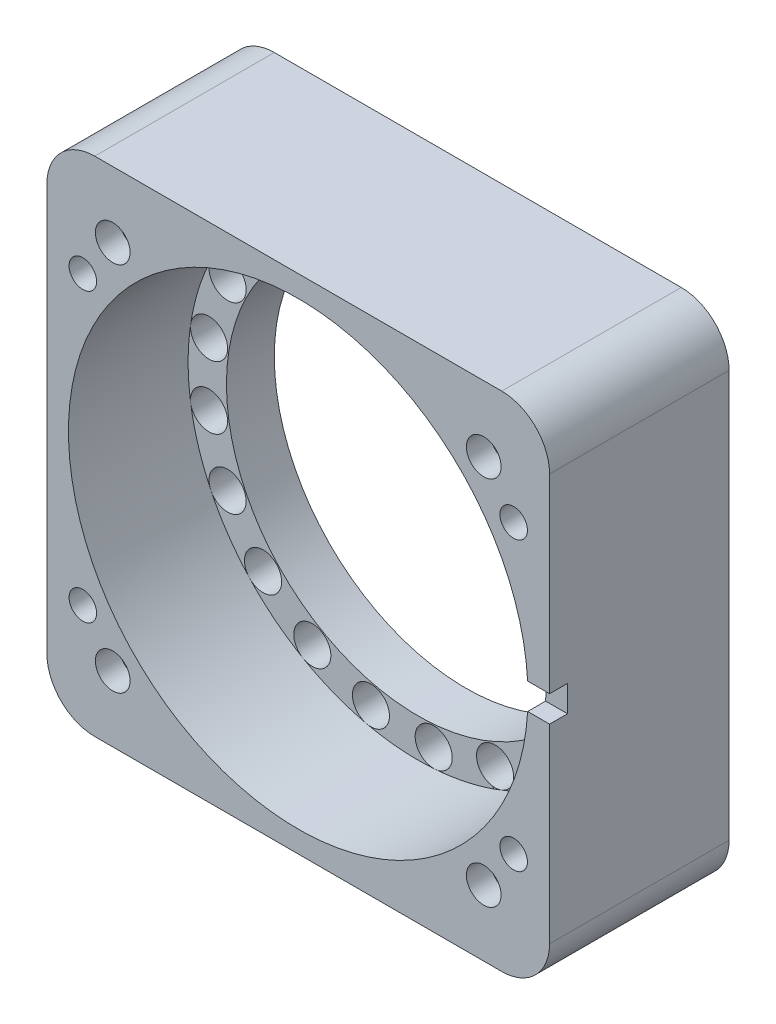
from build123d import *

# Parameters (mm, degrees)
SKETCH_1_W               = 42
SKETCH_1_H               = 42
EXTRUDE_1_DEPTH          = 15
FILLET_2_R               = 4
SKETCH_25_R              = 1.15
CUT_EXTRUDE_16_DEPTH     = 16
SKETCH_28_R              = 1.45
CUT_EXTRUDE_17_DEPTH     = 2
SKETCH_29_R              = 2.15
CUT_EXTRUDE_18_DEPTH     = 6
SKETCH_30_R              = 19.2
CUT_EXTRUDE_19_DEPTH     = 16
SKETCH_31_R              = 19.35
SKETCH_31_R_2            = 16
EXTRUDE_2_DEPTH          = 5
SKETCH_32_R              = 1.55
CUT_EXTRUDE_22_DEPTH     = 3
PATTERN_CIRCULAR_1_COUNT = 21
SKETCH_33_R              = 18.75
CUT_EXTRUDE_23_DEPTH     = 1
SKETCH_34_W              = 5
SKETCH_34_H              = 2.2
CUT_EXTRUDE_24_DEPTH     = 1.5


with BuildPart() as part:
    # 草图1 → 凸台-拉伸1 (new body)
    with BuildSketch(Plane.XY):
        Rectangle(SKETCH_1_W, SKETCH_1_H)
    extrude(amount=EXTRUDE_1_DEPTH)

    # 圆角2
    fillet_2_edges = [part.edges().sort_by_distance(p)[0] for p in [
        (21, 21, 7.5),
        (21, -21, 7.5),
        (-21, -21, 7.5),
        (-21, 21, 7.5),
    ]]
    fillet(fillet_2_edges, radius=FILLET_2_R)

    # 草图25 → 切除-拉伸16 (cut, through all)
    with BuildSketch(Plane.XY.offset(15)):
        with Locations((-18, 12)):
            Circle(SKETCH_25_R)
        with Locations((18, 12)):
            Circle(SKETCH_25_R)
        with Locations((18, -12)):
            Circle(SKETCH_25_R)
        with Locations((-18, -12)):
            Circle(SKETCH_25_R)
    extrude(amount=-CUT_EXTRUDE_16_DEPTH, mode=Mode.SUBTRACT)

    # 草图28 → 切除-拉伸17 (cut)
    with BuildSketch(Plane.XY.offset(15)):
        with Locations((-15.5, 15.5)):
            Circle(SKETCH_28_R)
        with Locations((15.5, 15.5)):
            Circle(SKETCH_28_R)
        with Locations((15.5, -15.5)):
            Circle(SKETCH_28_R)
        with Locations((-15.5, -15.5)):
            Circle(SKETCH_28_R)
    extrude(amount=-CUT_EXTRUDE_17_DEPTH, mode=Mode.SUBTRACT)

    # 草图29 → 切除-拉伸18 (cut)
    with BuildSketch(Plane(origin=(0, 0, 0), x_dir=(-1, 0, 0), z_dir=(0, 0, -1))):
        with Locations((-16.970562748, 16.970562748)):
            Circle(SKETCH_29_R)
        with Locations((16.970562748, 16.970562748)):
            Circle(SKETCH_29_R)
        with Locations((16.970562748, -16.970562748)):
            Circle(SKETCH_29_R)
        with Locations((-16.970562748, -16.970562748)):
            Circle(SKETCH_29_R)
    extrude(amount=-CUT_EXTRUDE_18_DEPTH, mode=Mode.SUBTRACT)

    # 草图30 → 切除-拉伸19 (cut, through all)
    with BuildSketch(Plane.XY.offset(15)):
        Circle(SKETCH_30_R)
    extrude(amount=-CUT_EXTRUDE_19_DEPTH, mode=Mode.SUBTRACT)

    # 草图31 → 凸台-拉伸2 (add)
    with BuildSketch(Plane(origin=(0, 0, 0), x_dir=(-1, 0, 0), z_dir=(0, 0, -1))):
        Circle(SKETCH_31_R)
        Circle(SKETCH_31_R_2, mode=Mode.SUBTRACT)
    extrude(amount=-EXTRUDE_2_DEPTH)

    # 草图32 → 切除-拉伸22 (cut)
    with BuildSketch(Plane.XY.offset(5)):
        with Locations((17.65, 0)):
            Circle(SKETCH_32_R)
    cut_extrude_22 = extrude(amount=-CUT_EXTRUDE_22_DEPTH, mode=Mode.SUBTRACT)

    # 阵列(圆周)1: 切除-拉伸22 ×21 about axis
    pattern_circular_1_axis = Axis((0, 0, 0), (0, 0, 1))
    for i in range(1, PATTERN_CIRCULAR_1_COUNT):
        add(cut_extrude_22.rotate(pattern_circular_1_axis, i * 360 / PATTERN_CIRCULAR_1_COUNT), mode=Mode.SUBTRACT)

    # 草图33 → 切除-拉伸23 (cut)
    with BuildSketch(Plane(origin=(0, 0, 0), x_dir=(-1, 0, 0), z_dir=(0, 0, -1))):
        Circle(SKETCH_33_R)
    extrude(amount=-CUT_EXTRUDE_23_DEPTH, mode=Mode.SUBTRACT)

    # 草图34 → 切除-拉伸24 (cut)
    with BuildSketch(Plane.XY.offset(15)):
        with Locations((20.745401418, 0)):
            Rectangle(SKETCH_34_W, SKETCH_34_H)
    extrude(amount=-CUT_EXTRUDE_24_DEPTH, mode=Mode.SUBTRACT)


solid = part.part
